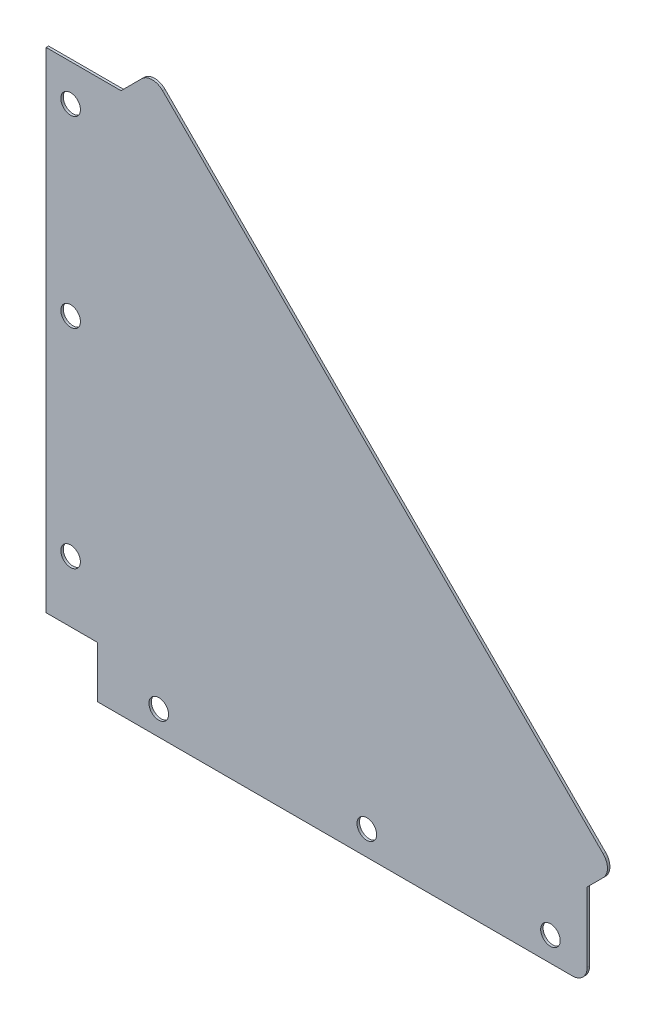
from build123d import *

# Parameters (mm, degrees)
SKETCH_1_R      = 4
EXTRUDE_1_DEPTH = 1


with BuildPart() as part:
    # 草圖1 → 填料-伸長1 (new body)
    with BuildSketch(Plane.XY):
        with BuildLine():
            Line((0, 21), (21, 21))
            Line((21, 21), (21, 0))
            Line((21, 0), (215, 0))
            ThreePointArc((215, 0), (219.242640687, 1.757359313), (221, 6))
            Line((221, 6), (221, 34.5))
            Line((221, 34.5), (227.535533906, 41.035533906))
            ThreePointArc((227.535533906, 41.035533906), (229.292893219, 45.278174593), (227.535533906, 49.52081528))
            Line((227.535533906, 49.52081528), (47.571067812, 229.485281374))
            ThreePointArc((47.571067812, 229.485281374), (43.328427125, 231.242640687), (39.085786438, 229.485281374))
            Line((39.085786438, 229.485281374), (30.600505063, 221))
            Line((30.600505063, 221), (0, 221))
            Line((0, 221), (0, 21))
        make_face()
        with Locations((10, 206)):
            Circle(SKETCH_1_R, mode=Mode.SUBTRACT)
        with Locations((10, 46)):
            Circle(SKETCH_1_R, mode=Mode.SUBTRACT)
        with Locations((10, 131)):
            Circle(SKETCH_1_R, mode=Mode.SUBTRACT)
        with Locations((46, 10)):
            Circle(SKETCH_1_R, mode=Mode.SUBTRACT)
        with Locations((131, 10)):
            Circle(SKETCH_1_R, mode=Mode.SUBTRACT)
        with Locations((206, 10)):
            Circle(SKETCH_1_R, mode=Mode.SUBTRACT)
    extrude(amount=EXTRUDE_1_DEPTH)


solid = part.part
